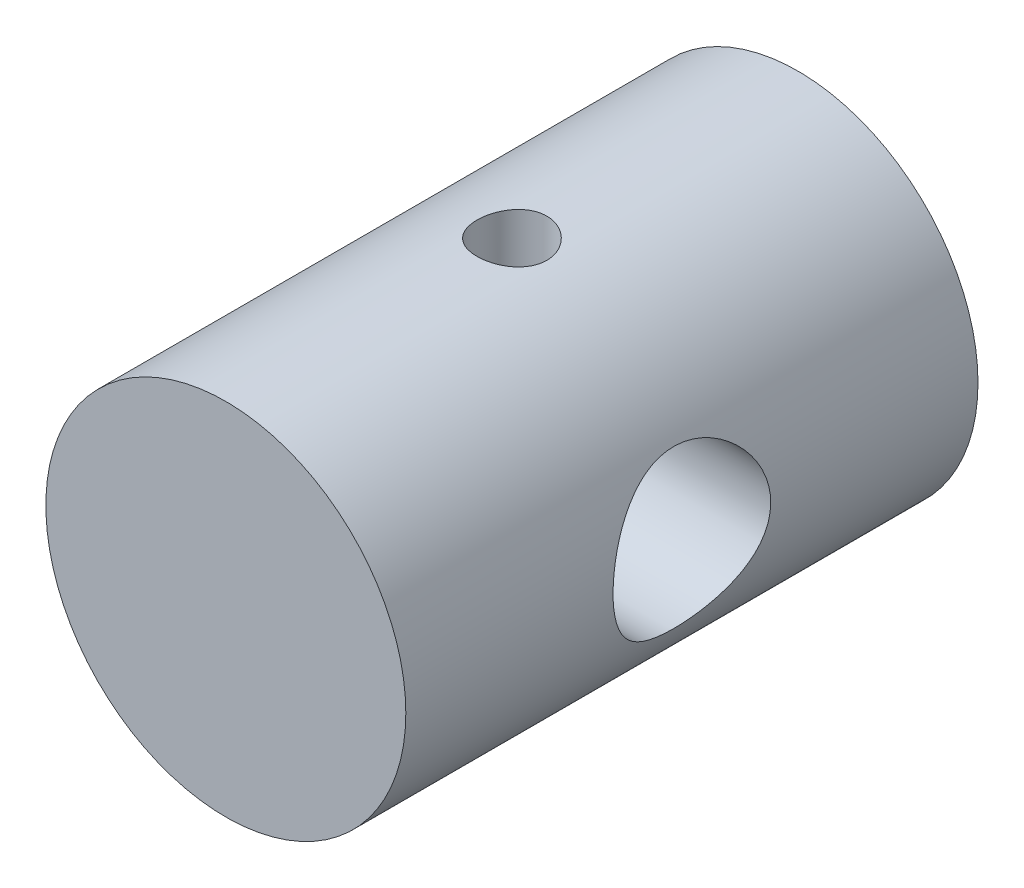
from build123d import *

# Parameters (mm, degrees)
SKETCH1_R               = 7.99
EXTRUDE1_DEPTH          = 25.4
SKETCH2_R               = 3.5
CUT_EXTRUDE2_DEPTH      = 8.99
CUT_EXTRUDE2_DEPTH_BACK = 8.99
SKETCH3_R               = 1.55
CUT_EXTRUDE3_DEPTH      = 8.9900001
CUT_EXTRUDE3_DEPTH_BACK = 8.9900001


with BuildPart() as part:
    # Sketch1 → Extrude1 (new body)
    with BuildSketch(Plane.XY):
        Circle(SKETCH1_R)
    extrude(amount=EXTRUDE1_DEPTH)

    # Sketch2 → Cut-Extrude2 (cut, two sides)
    with BuildSketch(Plane(origin=(0, 0, 0), x_dir=(0, 0, -1), z_dir=(1, 0, 0))) as cut_extrude2_sk:
        with Locations((-12.7, 0)):
            Circle(SKETCH2_R)
    extrude(amount=CUT_EXTRUDE2_DEPTH, mode=Mode.SUBTRACT)
    extrude(cut_extrude2_sk.sketch, amount=-CUT_EXTRUDE2_DEPTH_BACK, mode=Mode.SUBTRACT)

    # Sketch3 → Cut-Extrude3 (cut, two sides)
    with BuildSketch(Plane(origin=(0, 0, 0), x_dir=(1, 0, 0), z_dir=(0, 1, 0))) as cut_extrude3_sk:
        with Locations((0, -12.7)):
            Circle(SKETCH3_R)
    extrude(amount=CUT_EXTRUDE3_DEPTH, mode=Mode.SUBTRACT)
    extrude(cut_extrude3_sk.sketch, amount=-CUT_EXTRUDE3_DEPTH_BACK, mode=Mode.SUBTRACT)


solid = part.part
